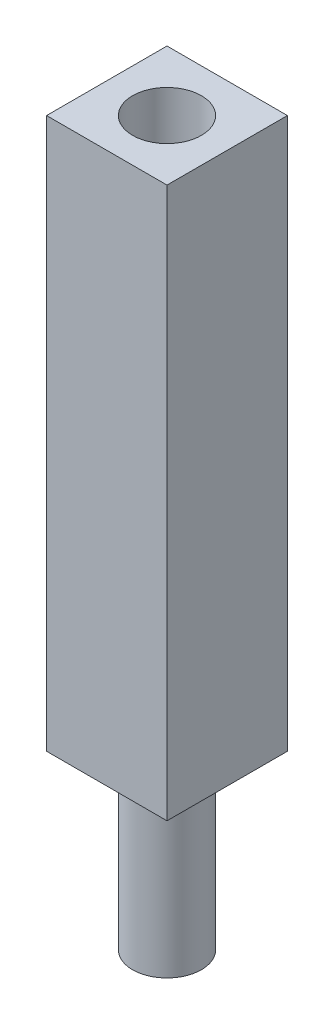
from build123d import *

# Parameters (mm, degrees)
SKETCH1_R           = 2
BOSS_EXTRUDE1_DEPTH = 10
BOSS_EXTRUDE2_START = 10
SKETCH1_3_W         = 7
SKETCH1_3_H         = 7
BOSS_EXTRUDE2_DEPTH = 2
BOSS_EXTRUDE3_START = 12
SKETCH1_4_W         = 7
SKETCH1_4_H         = 7
SKETCH1_4_R         = 2
BOSS_EXTRUDE3_DEPTH = 30


with BuildPart() as part:
    # Sketch1 → Boss-Extrude1 (new body)
    with BuildSketch(Plane(origin=(0, 0, 0), x_dir=(1, 0, 0), z_dir=(0, 1, 0))):
        Circle(SKETCH1_R)
    extrude(amount=BOSS_EXTRUDE1_DEPTH)

    # Sketch1_3 → Boss-Extrude2 (add)
    with BuildSketch(Plane(origin=(0, 0, 0), x_dir=(1, 0, 0), z_dir=(0, 1, 0)).offset(BOSS_EXTRUDE2_START)):
        Rectangle(SKETCH1_3_W, SKETCH1_3_H)
    extrude(amount=BOSS_EXTRUDE2_DEPTH)

    # Sketch1_4 → Boss-Extrude3 (add)
    with BuildSketch(Plane(origin=(0, 0, 0), x_dir=(1, 0, 0), z_dir=(0, 1, 0)).offset(BOSS_EXTRUDE3_START)):
        Rectangle(SKETCH1_4_W, SKETCH1_4_H)
        Circle(SKETCH1_4_R, mode=Mode.SUBTRACT)
    extrude(amount=BOSS_EXTRUDE3_DEPTH)


solid = part.part
